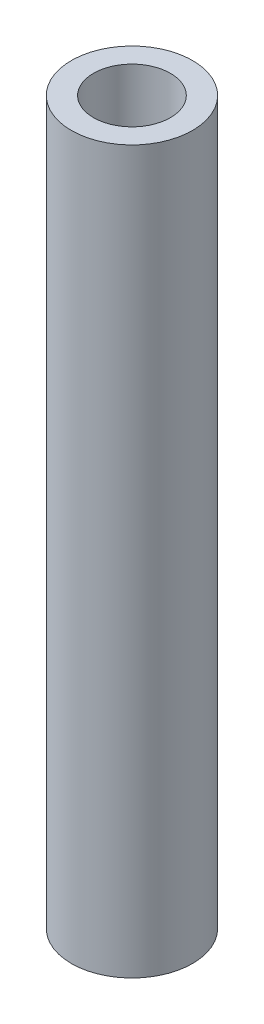
from build123d import *

# Parameters (mm, degrees)
SKETCH3_R           = 4.1
SKETCH3_R_2         = 2.602252049
BOSS_EXTRUDE3_DEPTH = 24.405


with BuildPart() as part:
    # Sketch3 → Boss-Extrude3 (new body, symmetric)
    with BuildSketch(Plane(origin=(0, 0, 0), x_dir=(1, 0, 0), z_dir=(0, 1, 0))):
        Circle(SKETCH3_R)
        Circle(SKETCH3_R_2, mode=Mode.SUBTRACT)
    extrude(amount=BOSS_EXTRUDE3_DEPTH, both=True)


solid = part.part
